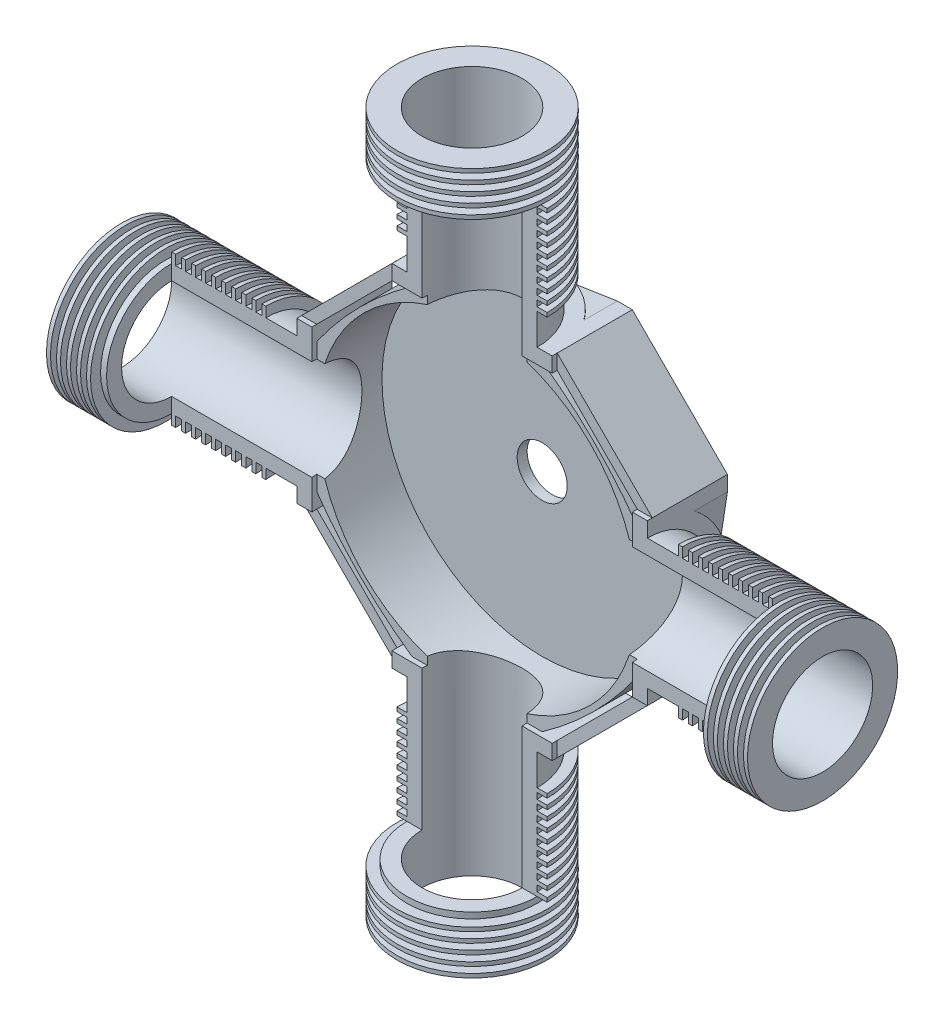
from build123d import *
from build123d.topology import SkipClean

# Parameters (mm, degrees)
SKETCH6_R               = 160
SKETCH6_R_2             = 25
BOSS_EXTRUDE2_DEPTH     = 10
SKETCH8_9_W             = 65
SKETCH8_9_H             = 140
CUT_EXTRUDE1_DEPTH      = 417.773319683
CUT_EXTRUDE1_DEPTH_BACK = 417.773319683
CIRPATTERN3_COUNT       = 4
SKETCH12_R              = 160
BOSS_EXTRUDE4_DEPTH     = 75
CUT_EXTRUDE2_DEPTH      = 519.67619957
CIRPATTERN4_COUNT       = 4


with BuildPart() as part:
    # Sketch6 → Boss-Extrude2 (new body)
    with BuildSketch(Plane.XY):
        Circle(SKETCH6_R)
        Circle(SKETCH6_R_2, mode=Mode.SUBTRACT)
    extrude(amount=BOSS_EXTRUDE2_DEPTH)



with BuildPart() as body_2:
    # Sketch8 → Revolve5 (revolve)
    with BuildSketch(Plane(origin=(0, 0, 0), x_dir=(0, 0, -1), z_dir=(1, 0, 0)), mode=Mode.PRIVATE) as revolve5_sk:
        Polygon((-10, 160), (-30, 160), (-30, 350), (-15, 350), (-5, 350), (-5, 346), (-15, 346), (-15, 340), (-5, 340), (-5, 336), (-15, 336), (-15, 330), (-5, 330), (-5, 326), (-15, 326), (-15, 320), (-5, 320), (-5, 316), (-15, 316), (-15, 310), (-5, 310), (-5, 306), (-15, 306), (-15, 300), (-5, 300), (-5, 296), (-15, 296), (-15, 290), (-5, 290), (-5, 286), (-15, 286), (-15, 280), (-5, 280), (-5, 276), (-15, 276), (-15, 270), (-5, 270), (-5, 266), (-15, 266), (-15, 260), (-5, 260), (-5, 256), (-15, 256), (-15, 250), (-5, 250), (-5, 246), (-15, 246), (-15, 240), (-5, 240), (-5, 236), (-15, 236), (-15, 230), (-5, 230), (-5, 226), (-15, 226), (-15, 220), (-5, 220), (-5, 216), (-15, 216), (-15, 210), (-5, 210), (-5, 206), (-15, 206), (-15, 175), (0, 175), (0, 160), align=None)
    revolve(revolve5_sk.sketch.rotate(Axis((0, 300, 80), (0, -1, 0)), 180), axis=Axis((0, 300, 80), (0, -1, 0)))

    # Sketch8_9 → Cut-Extrude1 (cut, two sides)
    with BuildSketch(Plane(origin=(0, 0, 0), x_dir=(0, 0, -1), z_dir=(1, 0, 0))) as cut_extrude1_sk:
        with Locations((-112.5, 230)):
            Rectangle(SKETCH8_9_W, SKETCH8_9_H)
    extrude(amount=CUT_EXTRUDE1_DEPTH, mode=Mode.SUBTRACT)
    extrude(cut_extrude1_sk.sketch, amount=-CUT_EXTRUDE1_DEPTH_BACK, mode=Mode.SUBTRACT)


with BuildPart() as cut_extrude1_kept_piece:
    # of the separate pieces the step leaves, the one the design keeps (cut_extrude1_pieces_kept)
    add(body_2.part.solids().sort_by_distance((-50, 160, 80))[0])


with BuildPart() as cirpattern3_1:
    # CirPattern3: pattern copy
    add(cut_extrude1_kept_piece.part.rotate(Axis((0, 0, 0), (0, 0, 1)), 1 * 360 / CIRPATTERN3_COUNT))


with BuildPart() as cirpattern3_2:
    # CirPattern3: pattern copy
    add(cut_extrude1_kept_piece.part.rotate(Axis((0, 0, 0), (0, 0, 1)), 2 * 360 / CIRPATTERN3_COUNT))


with BuildPart() as cirpattern3_3:
    # CirPattern3: pattern copy
    add(cut_extrude1_kept_piece.part.rotate(Axis((0, 0, 0), (0, 0, 1)), 3 * 360 / CIRPATTERN3_COUNT))


with BuildPart() as part_1:
    add(part.part)

    add(cut_extrude1_kept_piece.part)  # Boss-Extrude4 merges Cut-Extrude1 kept piece

    add(cirpattern3_1.part)  # Boss-Extrude4 merges CirPattern3_1

    add(cirpattern3_2.part)  # Boss-Extrude4 merges CirPattern3_2

    add(cirpattern3_3.part)  # Boss-Extrude4 merges CirPattern3_3
    # Sketch12 → Boss-Extrude4 (add)
    with BuildSketch(Plane.XY):
        Polygon((-175, 80), (-80, 175), (-65, 175), (0, 165), (65, 175), (80, 175), (175, 80), (175, 65), (165, 0), (175, -65), (175, -80), (80, -175), (65, -175), (0, -165), (-65, -175), (-80, -175), (-175, -80), (-175, -65), (-165, 0), (-175, 65), align=None)
        Circle(SKETCH12_R, mode=Mode.SUBTRACT)
        with BuildLine():
            Line((-160, 80), (-80, 160))
            Line((-80, 160), (-65, 160))
            ThreePointArc((-65, 160), (-116.642623882, 116.642623882), (-160, 65))
            Line((-160, 65), (-160, 80))
        make_face(mode=Mode.SUBTRACT)
        with BuildLine():
            Line((80, 160), (160, 80))
            Line((160, 80), (160, 65))
            ThreePointArc((160, 65), (116.642623882, 116.642623882), (65, 160))
            Line((65, 160), (80, 160))
        make_face(mode=Mode.SUBTRACT)
        with BuildLine():
            Line((160, -80), (80, -160))
            Line((80, -160), (65, -160))
            ThreePointArc((65, -160), (116.642623882, -116.642623882), (160, -65))
            Line((160, -65), (160, -80))
        make_face(mode=Mode.SUBTRACT)
        with BuildLine():
            Line((-80, -160), (-160, -80))
            Line((-160, -80), (-160, -65))
            ThreePointArc((-160, -65), (-116.642623882, -116.642623882), (-65, -160))
            Line((-65, -160), (-80, -160))
        make_face(mode=Mode.SUBTRACT)
    extrude(amount=BOSS_EXTRUDE4_DEPTH)

    # Sketch13 → Cut-Extrude2 (cut, through all)
    with SkipClean():  # the faces are left unmerged after this step: merging them gives an invalid solid
        with BuildSketch(Plane(origin=(0, 0, 0), x_dir=(1, 0, 0), z_dir=(0, 1, 0))):
            with BuildLine():
                Line((-49.749371855, -75), (49.749371855, -75))
                ThreePointArc((49.749371855, -75), (0, -30), (-49.749371855, -75))
            make_face()
        cut_extrude2 = extrude(amount=-CUT_EXTRUDE2_DEPTH, mode=Mode.SUBTRACT)

    # CirPattern4: Cut-Extrude2 ×4 about axis
    with SkipClean():  # the faces are left unmerged after this step: merging them gives an invalid solid
        cirpattern4_axis = Axis((0, 0, 10), (0, 0, 1))
        for i in range(1, CIRPATTERN4_COUNT):
            add(cut_extrude2.rotate(cirpattern4_axis, i * 360 / CIRPATTERN4_COUNT), mode=Mode.SUBTRACT)


solid = part_1.part
